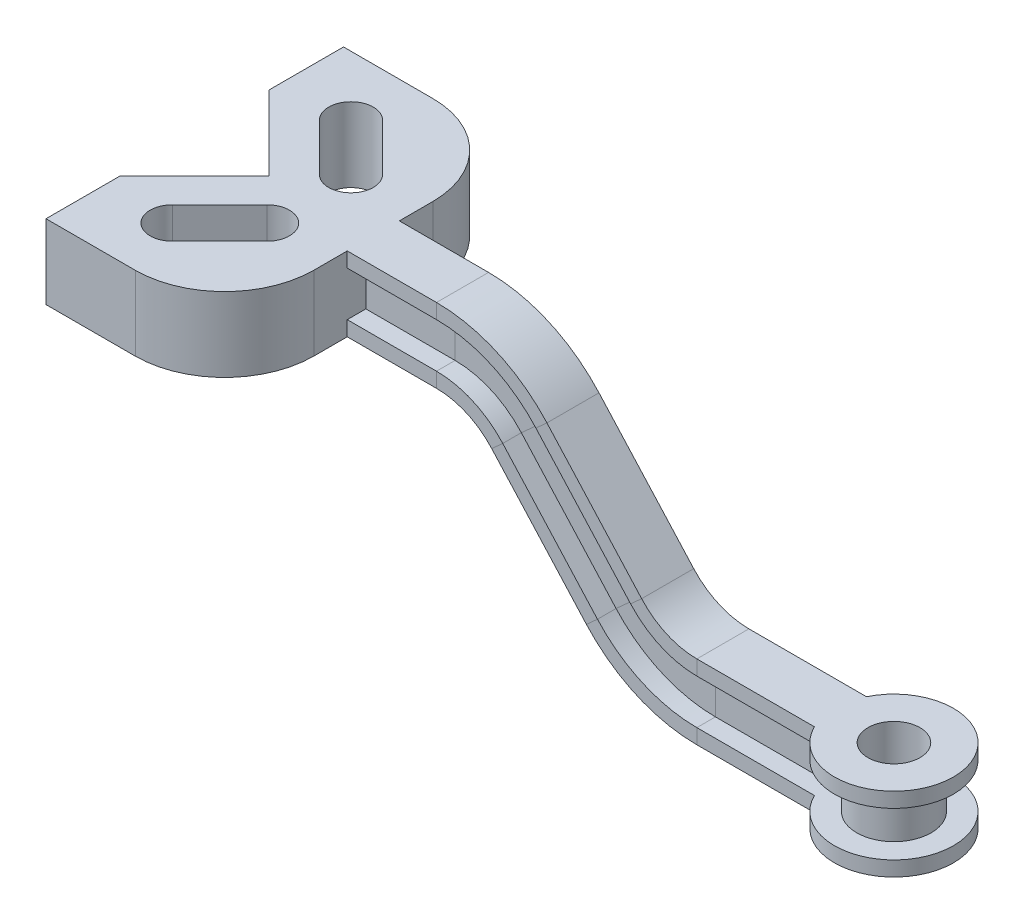
from build123d import *

# Parameters (mm, degrees)
EXTRUDE_1_DEPTH     = 50
SKETCH_5_R          = 17.5
CUT_EXTRUDE_1_DEPTH = 51


with BuildPart() as part:
    # 草圖1 → 填料-伸長1 (new body)
    with BuildSketch(Plane(origin=(0, 0, 0), x_dir=(1, 0, 0), z_dir=(0, 1, 0))):
        with BuildLine():
            Line((-120, 100), (-60, 100))
            ThreePointArc((-60, 100), (-17.573593129, 82.426406871), (0, 40))
            Line((0, 40), (0, -40))
            ThreePointArc((0, -40), (-17.573593129, -82.426406871), (-60, -100))
            Line((-60, -100), (-120, -100))
            Line((-120, -100), (-120, -50))
            Line((-120, -50), (-70, 0))
            Line((-70, 0), (-120, 50))
            Line((-120, 50), (-120, 100))
        make_face()
        with BuildLine():
            Line((-64.393398282, 70.606601718), (-32.573593129, 38.786796564))
            ThreePointArc((-32.573593129, 38.786796564), (-32.573593129, 17.573593129), (-53.786796564, 17.573593129))
            Line((-53.786796564, 17.573593129), (-85.606601718, 49.393398282))
            ThreePointArc((-85.606601718, 49.393398282), (-85.606601718, 70.606601718), (-64.393398282, 70.606601718))
        make_face(mode=Mode.SUBTRACT)
        with BuildLine():
            Line((-64.393398282, -70.606601718), (-32.573593129, -38.786796564))
            ThreePointArc((-32.573593129, -38.786796564), (-32.573593129, -17.573593129), (-53.786796564, -17.573593129))
            Line((-53.786796564, -17.573593129), (-85.606601718, -49.393398282))
            ThreePointArc((-85.606601718, -49.393398282), (-85.606601718, -70.606601718), (-64.393398282, -70.606601718))
        make_face(mode=Mode.SUBTRACT)
    extrude(amount=EXTRUDE_1_DEPTH)

    # 掃出1: sweep along a path in 草圖2
    with BuildLine(Plane.XY) as sweep_1_path:
        Line((0, 50), (60, 50))
        ThreePointArc((60, 50), (100.613846605, 41.381154862), (134.226804124, 17.010309278))
        Line((134.226804124, 17.010309278), (197.886597938, -53.505154639))
        ThreePointArc((197.886597938, -53.505154639), (214.693076697, -65.690577431), (235, -70))
        Line((235, -70), (350, -70))
    # 草圖3 → 掃出1 (sweep)
    with BuildSketch(Plane(origin=(0, 0, 0), x_dir=(0, 0, -1), z_dir=(1, 0, 0))):
        Polygon((17.5, 50), (-17.5, 50), (-17.5, 40), (-5, 40), (-5, 10), (-17.5, 10), (-17.5, 0), (17.5, 0), (17.5, 10), (5, 10), (5, 40), (17.5, 40), align=None)
    sweep(path=sweep_1_path.line)

    # 草圖4 → 旋轉1 (revolve)
    with BuildSketch(Plane.XY):
        Polygon((350, -70), (390, -70), (390, -80), (375, -80), (375, -110), (390, -110), (390, -120), (350, -120), align=None)
    revolve(axis=Axis((350, -47.23777031, 0), (0, -1, 0)))

    # 草圖5 → 除料-伸長1 (cut, through all)
    with BuildSketch(Plane(origin=(0, -70, 0), x_dir=(1, 0, 0), z_dir=(0, 1, 0))):
        with Locations((350, 0)):
            Circle(SKETCH_5_R)
    extrude(amount=-CUT_EXTRUDE_1_DEPTH, mode=Mode.SUBTRACT)


solid = part.part
